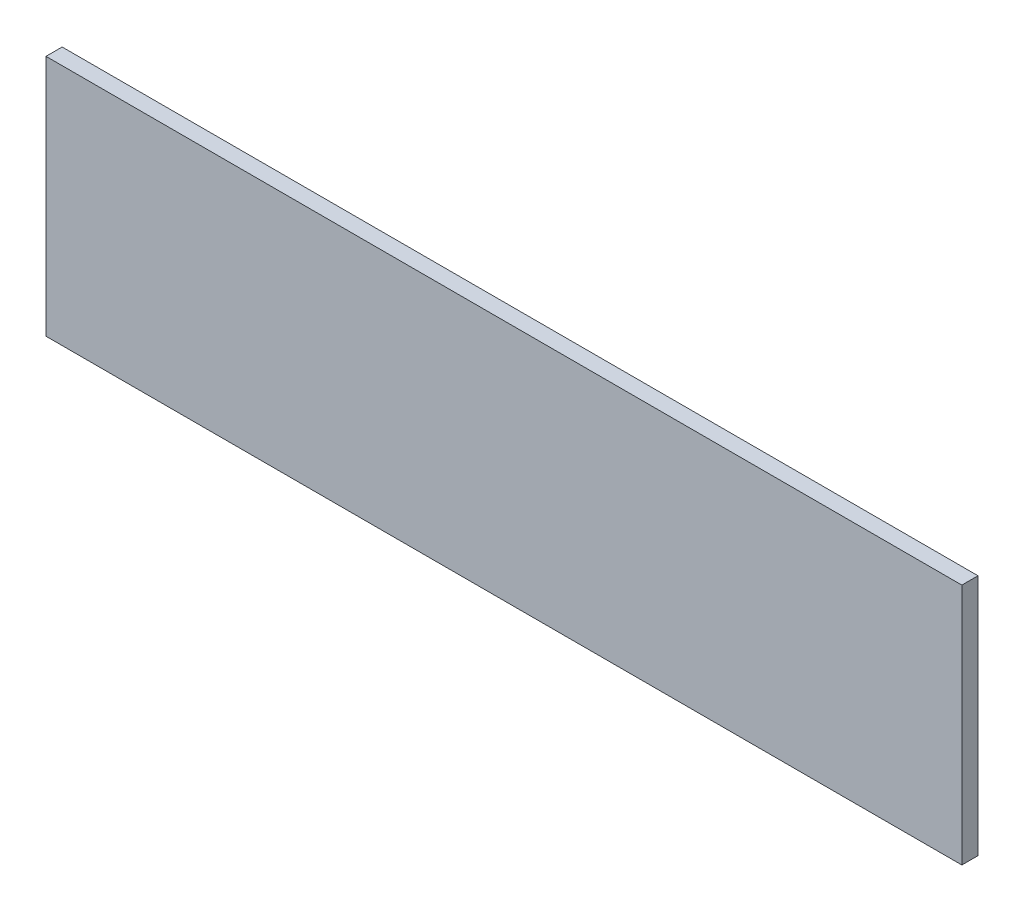
from build123d import *

# Parameters (mm, degrees)
CROQUIS1_W              = 170
CROQUIS1_H              = 45
SALIENTE_EXTRUIR1_DEPTH = 3


with BuildPart() as part:
    # Croquis1 → Saliente-Extruir1 (new body)
    with BuildSketch(Plane.XY):
        with Locations((85, 22.5)):
            Rectangle(CROQUIS1_W, CROQUIS1_H)
    extrude(amount=SALIENTE_EXTRUIR1_DEPTH)


solid = part.part
